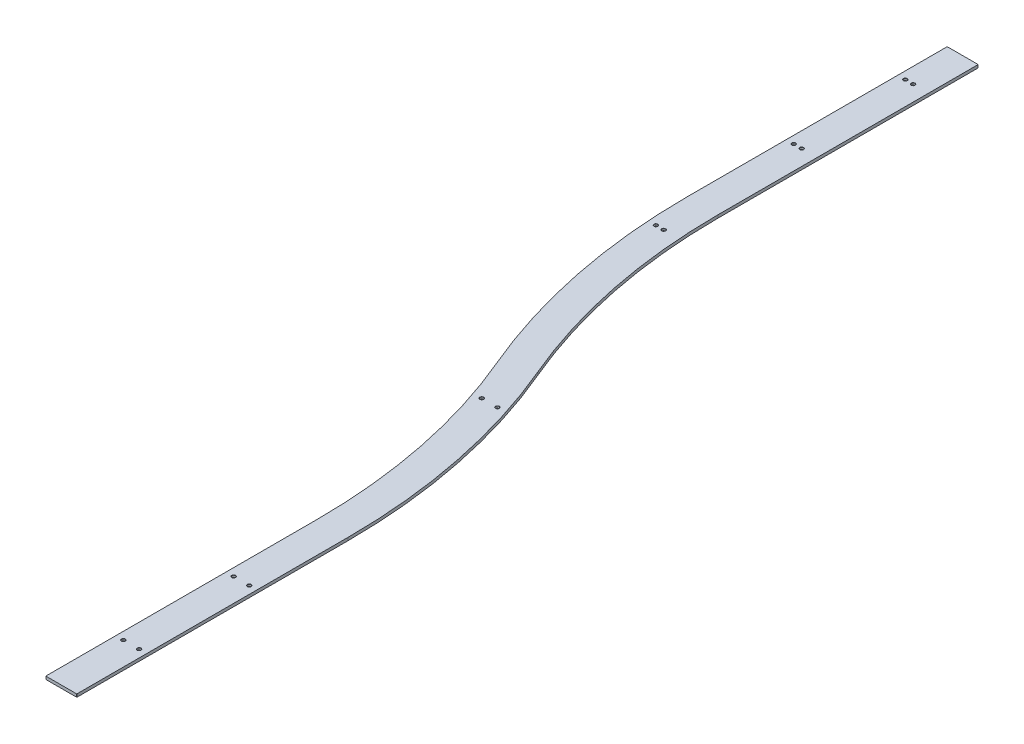
from build123d import *

# Parameters (mm, degrees)
EXTRUDE_THIN1_DEPTH                           = 9.525
FILLET1_R                                     = 1
CBORE_FOR_1_4_SOCKET_HEAD_CAP_SCREW3_AT_COUNT = 2
CBORE_FOR_1_4_SOCKET_HEAD_CAP_SCREW3_AT_PITCH = 25.4
CBORE_FOR_1_4_SOCKET_HEAD_CAP_SCREW3_2_COUNT  = 2
CBORE_FOR_1_4_SOCKET_HEAD_CAP_SCREW3_2_PITCH  = 360
CBORE_FOR_1_4_SOCKET_HEAD_CAP_SCREW3_3_COUNT  = 2
CBORE_FOR_1_4_SOCKET_HEAD_CAP_SCREW3_3_PITCH  = 360.894943162
CBORE_FOR_1_4_SOCKET_HEAD_CAP_SCREW3_4_COUNT  = 2
CBORE_FOR_1_4_SOCKET_HEAD_CAP_SCREW3_4_PITCH  = 810.011979082
CBORE_FOR_1_4_SOCKET_HEAD_CAP_SCREW3_5_COUNT  = 2
CBORE_FOR_1_4_SOCKET_HEAD_CAP_SCREW3_5_PITCH  = 810.272040359
CBORE_FOR_1_4_SOCKET_HEAD_CAP_SCREW3_6_COUNT  = 2
CBORE_FOR_1_4_SOCKET_HEAD_CAP_SCREW3_6_PITCH  = 1592.054190081
CBORE_FOR_1_4_SOCKET_HEAD_CAP_SCREW3_7_COUNT  = 2
CBORE_FOR_1_4_SOCKET_HEAD_CAP_SCREW3_7_PITCH  = 1585.435257008
CBORE_FOR_1_4_SOCKET_HEAD_CAP_SCREW3_8_COUNT  = 2
CBORE_FOR_1_4_SOCKET_HEAD_CAP_SCREW3_8_PITCH  = 2495.888736841
CBORE_FOR_1_4_SOCKET_HEAD_CAP_SCREW3_9_COUNT  = 2
CBORE_FOR_1_4_SOCKET_HEAD_CAP_SCREW3_9_PITCH  = 2489.677269585
CBORE_FOR_1_4_SOCKET_HEAD_CAP_SCREW3_10_COUNT = 2
CBORE_FOR_1_4_SOCKET_HEAD_CAP_SCREW3_10_PITCH = 2849.198490804
CBORE_FOR_1_4_SOCKET_HEAD_CAP_SCREW3_11_COUNT = 2
CBORE_FOR_1_4_SOCKET_HEAD_CAP_SCREW3_11_PITCH = 2843.758843503


with BuildPart() as part:
    # Sketch1 → Extrude-Thin1 (new body)
    with BuildSketch(Plane(origin=(0, 0, 0), x_dir=(1, 0, 0), z_dir=(0, 1, 0))):
        with BuildLine():
            Line((50, 74.1), (50, 950))
            ThreePointArc((50, 950), (10.51327528, 1342.620137537), (-106.365295977, 1719.514251857))
            ThreePointArc((-106.365295977, 1719.514251857), (-217.315977346, 2077.292913403), (-254.8, 2450))
            Line((-254.8, 2450), (-254.8, 3290))
            Line((-254.8, 3290), (-354.8, 3290))
            Line((-354.8, 3290), (-354.8, 2450))
            ThreePointArc((-354.8, 2450), (-315.31327528, 2057.379862463), (-198.434704023, 1680.485748143))
            ThreePointArc((-198.434704023, 1680.485748143), (-87.484022654, 1322.707086597), (-50, 950))
            Line((-50, 950), (-50, 74.1))
            Line((-50, 74.1), (50, 74.1))
        make_face()
    extrude(amount=EXTRUDE_THIN1_DEPTH)

    # Fillet1
    fillet1_edges = [part.edges().sort_by_distance(p)[0] for p in [
        (50, 4.7625, -74.1),
        (-50, 4.7625, -74.1),
        (-354.8, 4.7625, -3290),
        (-254.8, 4.7625, -3290),
    ]]
    fillet(fillet1_edges, radius=FILLET1_R)

    # Sketch7 → CBORE for 1/4 Socket Head Cap Screw3 (revolve, cut)
    with BuildSketch(Plane(origin=(-304.8, 9.525, -3130), x_dir=(0, 0, 1), z_dir=(1, 0, 0))):
        Polygon((0, 0), (0, 9.525), (4.0132, 9.525), (3.3782, 8.89), (3.3782, 6.35), (5.55625, 6.35), (5.55625, 0.635), (6.19125, 0), align=None)
    cbore_for_1_4_socket_head_cap_screw3 = revolve(axis=Axis((-304.8, 15.875, -3130), (0, -1, 0)), mode=Mode.SUBTRACT)

    # CBORE for 1/4 Socket Head Cap Screw3 at: CBORE for 1/4 Socket Head Cap Screw3 ×2
    with Locations(*[(-i * CBORE_FOR_1_4_SOCKET_HEAD_CAP_SCREW3_AT_PITCH, 0, 0) for i in range(1, CBORE_FOR_1_4_SOCKET_HEAD_CAP_SCREW3_AT_COUNT)]):
        add(cbore_for_1_4_socket_head_cap_screw3, mode=Mode.SUBTRACT)

    # CBORE for 1_4 Socket Head Cap Screw3 2: CBORE for 1/4 Socket Head Cap Screw3 ×2
    with Locations(*[(0, 0, i * CBORE_FOR_1_4_SOCKET_HEAD_CAP_SCREW3_2_PITCH) for i in range(1, CBORE_FOR_1_4_SOCKET_HEAD_CAP_SCREW3_2_COUNT)]):
        add(cbore_for_1_4_socket_head_cap_screw3, mode=Mode.SUBTRACT)

    # CBORE for 1_4 Socket Head Cap Screw3 3: CBORE for 1/4 Socket Head Cap Screw3 ×2
    with Locations(*[Vector(-0.070380593, 0, 0.997520211) * (i * CBORE_FOR_1_4_SOCKET_HEAD_CAP_SCREW3_3_PITCH) for i in range(1, CBORE_FOR_1_4_SOCKET_HEAD_CAP_SCREW3_3_COUNT)]):
        add(cbore_for_1_4_socket_head_cap_screw3, mode=Mode.SUBTRACT)

    # CBORE for 1_4 Socket Head Cap Screw3 4: CBORE for 1/4 Socket Head Cap Screw3 ×2
    with Locations(*[Vector(0.005438504, 0, 0.999985211) * (i * CBORE_FOR_1_4_SOCKET_HEAD_CAP_SCREW3_4_PITCH) for i in range(1, CBORE_FOR_1_4_SOCKET_HEAD_CAP_SCREW3_4_COUNT)]):
        add(cbore_for_1_4_socket_head_cap_screw3, mode=Mode.SUBTRACT)

    # CBORE for 1_4 Socket Head Cap Screw3 5: CBORE for 1/4 Socket Head Cap Screw3 ×2
    with Locations(*[Vector(-0.025910738, 0, 0.99966426) * (i * CBORE_FOR_1_4_SOCKET_HEAD_CAP_SCREW3_5_PITCH) for i in range(1, CBORE_FOR_1_4_SOCKET_HEAD_CAP_SCREW3_5_COUNT)]):
        add(cbore_for_1_4_socket_head_cap_screw3, mode=Mode.SUBTRACT)

    # CBORE for 1_4 Socket Head Cap Screw3 6: CBORE for 1/4 Socket Head Cap Screw3 ×2
    with Locations(*[Vector(0.145977342, 0, 0.989287934) * (i * CBORE_FOR_1_4_SOCKET_HEAD_CAP_SCREW3_6_PITCH) for i in range(1, CBORE_FOR_1_4_SOCKET_HEAD_CAP_SCREW3_6_COUNT)]):
        add(cbore_for_1_4_socket_head_cap_screw3, mode=Mode.SUBTRACT)

    # CBORE for 1_4 Socket Head Cap Screw3 7: CBORE for 1/4 Socket Head Cap Screw3 ×2
    with Locations(*[Vector(0.114545099, 0, 0.993418049) * (i * CBORE_FOR_1_4_SOCKET_HEAD_CAP_SCREW3_7_PITCH) for i in range(1, CBORE_FOR_1_4_SOCKET_HEAD_CAP_SCREW3_7_COUNT)]):
        add(cbore_for_1_4_socket_head_cap_screw3, mode=Mode.SUBTRACT)

    # CBORE for 1_4 Socket Head Cap Screw3 8: CBORE for 1/4 Socket Head Cap Screw3 ×2
    with Locations(*[Vector(0.132297564, 0, 0.991210046) * (i * CBORE_FOR_1_4_SOCKET_HEAD_CAP_SCREW3_8_PITCH) for i in range(1, CBORE_FOR_1_4_SOCKET_HEAD_CAP_SCREW3_8_COUNT)]):
        add(cbore_for_1_4_socket_head_cap_screw3, mode=Mode.SUBTRACT)

    # CBORE for 1_4 Socket Head Cap Screw3 9: CBORE for 1/4 Socket Head Cap Screw3 ×2
    with Locations(*[Vector(0.112223381, 0, 0.993683004) * (i * CBORE_FOR_1_4_SOCKET_HEAD_CAP_SCREW3_9_PITCH) for i in range(1, CBORE_FOR_1_4_SOCKET_HEAD_CAP_SCREW3_9_COUNT)]):
        add(cbore_for_1_4_socket_head_cap_screw3, mode=Mode.SUBTRACT)

    # CBORE for 1_4 Socket Head Cap Screw3 10: CBORE for 1/4 Socket Head Cap Screw3 ×2
    with Locations(*[Vector(0.115892242, 0, 0.993261792) * (i * CBORE_FOR_1_4_SOCKET_HEAD_CAP_SCREW3_10_PITCH) for i in range(1, CBORE_FOR_1_4_SOCKET_HEAD_CAP_SCREW3_10_COUNT)]):
        add(cbore_for_1_4_socket_head_cap_screw3, mode=Mode.SUBTRACT)

    # CBORE for 1_4 Socket Head Cap Screw3 11: CBORE for 1/4 Socket Head Cap Screw3 ×2
    with Locations(*[Vector(0.098250244, 0, 0.99516174) * (i * CBORE_FOR_1_4_SOCKET_HEAD_CAP_SCREW3_11_PITCH) for i in range(1, CBORE_FOR_1_4_SOCKET_HEAD_CAP_SCREW3_11_COUNT)]):
        add(cbore_for_1_4_socket_head_cap_screw3, mode=Mode.SUBTRACT)


solid = part.part
